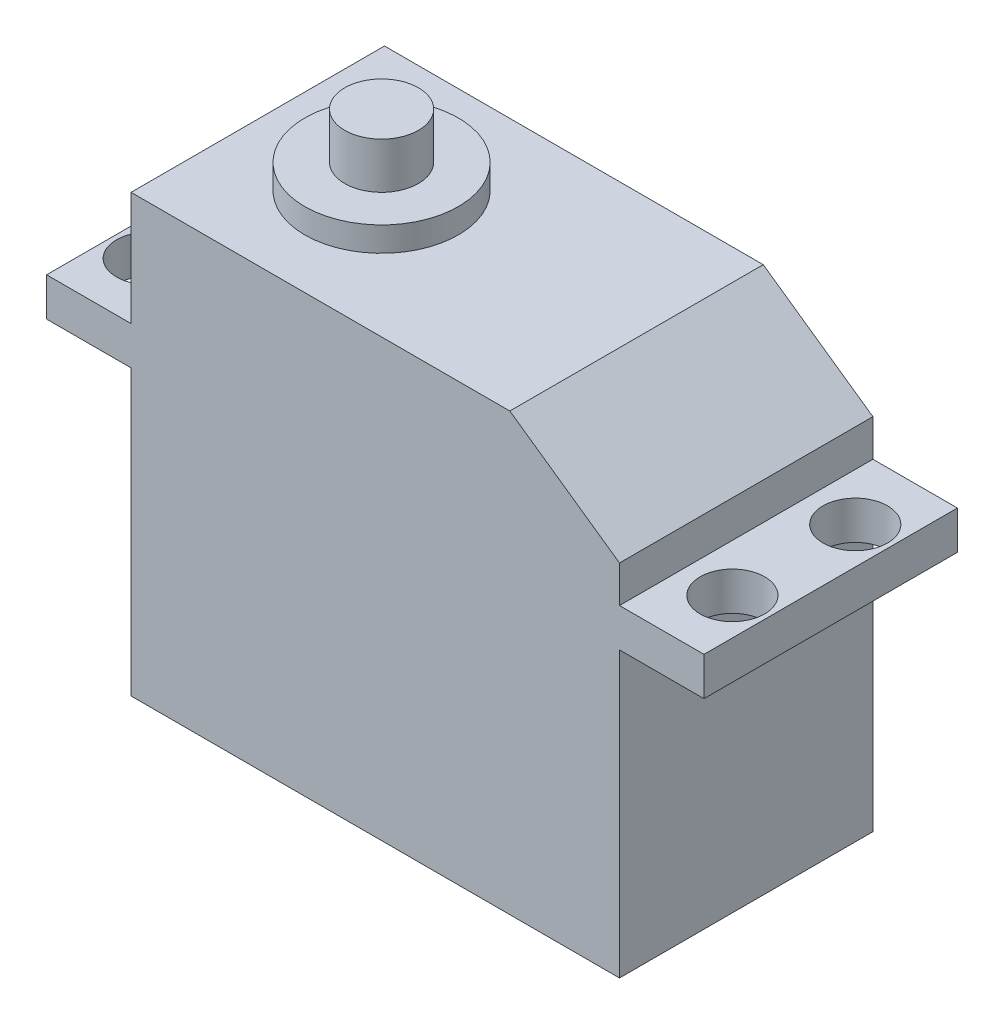
from build123d import *

# Parameters (mm, degrees)
SKETCH1_W           = 31.8
SKETCH1_H           = 16.5
BOSS_EXTRUDE1_DEPTH = 28.4
SKETCH2_W           = 16.5
SKETCH2_H           = 2.5
BOSS_EXTRUDE2_DEPTH = 5.5
SKETCH3_R           = 2.1
CUT_EXTRUDE1_DEPTH  = 2.5
SKETCH4_R           = 5
BOSS_EXTRUDE3_DEPTH = 1.6
SKETCH5_R           = 2.4
BOSS_EXTRUDE4_DEPTH = 3
CHAMFER1_SIZE       = 5
CHAMFER1_SIZE2      = 7.140740034


with BuildPart() as part:
    # Sketch1 → Boss-Extrude1 (new body)
    with BuildSketch(Plane(origin=(0, 0, 0), x_dir=(1, 0, 0), z_dir=(0, 1, 0))):
        Rectangle(SKETCH1_W, SKETCH1_H)
    extrude(amount=BOSS_EXTRUDE1_DEPTH)

    # Sketch2 → Boss-Extrude2 (add)
    with BuildSketch(Plane(origin=(15.9, 0, 0), x_dir=(0, 0, -1), z_dir=(1, 0, 0))):
        with Locations((0, 19.75)):
            Rectangle(SKETCH2_W, SKETCH2_H)
    boss_extrude2 = extrude(amount=BOSS_EXTRUDE2_DEPTH)

    # Mirror1: Boss-Extrude2 across plane
    add(boss_extrude2.mirror(Plane(origin=(0, 0, 0), x_dir=(0, 0, 1), z_dir=(1, 0, 0))))

    # Sketch3 → Cut-Extrude1 (cut)
    with BuildSketch(Plane(origin=(0, 21, 0), x_dir=(1, 0, 0), z_dir=(0, 1, 0))):
        with Locations((-19, 4)):
            Circle(SKETCH3_R)
        with Locations((-19, -4)):
            Circle(SKETCH3_R)
        with Locations((19, 4)):
            Circle(SKETCH3_R)
        with Locations((19, -4)):
            Circle(SKETCH3_R)
    extrude(amount=-CUT_EXTRUDE1_DEPTH, mode=Mode.SUBTRACT)

    # Sketch4 → Boss-Extrude3 (add)
    with BuildSketch(Plane(origin=(0, 28.4, 0), x_dir=(1, 0, 0), z_dir=(0, 1, 0))):
        with Locations((-7.84, 0)):
            Circle(SKETCH4_R)
    extrude(amount=BOSS_EXTRUDE3_DEPTH)

    # Sketch5 → Boss-Extrude4 (add)
    with BuildSketch(Plane(origin=(0, 30, 0), x_dir=(1, 0, 0), z_dir=(0, 1, 0))):
        with Locations((-7.84, 0)):
            Circle(SKETCH5_R)
    extrude(amount=BOSS_EXTRUDE4_DEPTH)

    # Chamfer1
    chamfer1_edges = [part.edges().sort_by_distance(p)[0] for p in [
        (15.9, 28.4, 0),
    ]]
    chamfer1_side = [part.faces().sort_by_distance(p)[0] for p in [
        (15.9, 24.7, 0),
    ]]
    chamfer(chamfer1_edges, length=CHAMFER1_SIZE, length2=CHAMFER1_SIZE2, reference=chamfer1_side[0])


solid = part.part
